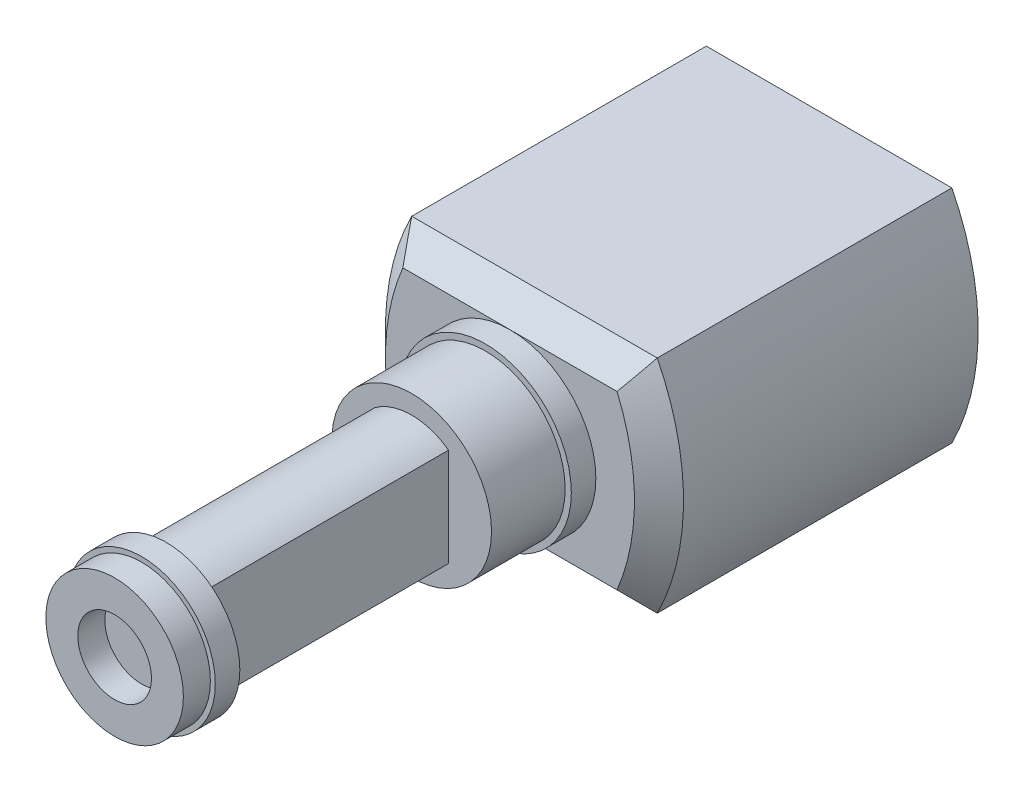
from build123d import *

# Parameters (mm, degrees)
BOSS_EXTRUDE1_DEPTH = 120
BOSS_EXTRUDE2_DEPTH = 10
BOSS_EXTRUDE2_TAPER = 45
SKETCH3_R           = 35
BOSS_EXTRUDE3_DEPTH = 10
SKETCH4_R           = 32.5
BOSS_EXTRUDE4_DEPTH = 30
BOSS_EXTRUDE5_DEPTH = 100
SKETCH6_R           = 30
BOSS_EXTRUDE6_DEPTH = 10
SKETCH7_R           = 28
BOSS_EXTRUDE7_DEPTH = 11
SKETCH8_R           = 40
BOSS_EXTRUDE8_DEPTH = 11
BOSS_EXTRUDE9_DEPTH = 55
SKETCH10_R          = 15
CUT_EXTRUDE1_DEPTH  = 11
SKETCH11_R          = 15
CUT_EXTRUDE2_DEPTH  = 20


with BuildPart() as part:
    # Sketch1 → Boss-Extrude1 (new body)
    with BuildSketch(Plane.XY):
        with BuildLine():
            Line((-50, 45), (50, 45))
            ThreePointArc((50, 45), (60.697144503, 0), (50, -45))
            Line((50, -45), (-50, -45))
            ThreePointArc((-50, -45), (-60.697144503, 0), (-50, 45))
        make_face()
    extrude(amount=BOSS_EXTRUDE1_DEPTH)

    # Sketch2 → Boss-Extrude2 (add)
    with BuildSketch(Plane.XY.offset(120)):
        with BuildLine():
            Line((-50, -45), (50, -45))
            ThreePointArc((50, -45), (60.697144503, 0), (50, 45))
            Line((50, 45), (-50, 45))
            ThreePointArc((-50, 45), (-60.697144503, 0), (-50, -45))
        make_face()
    extrude(amount=BOSS_EXTRUDE2_DEPTH, taper=BOSS_EXTRUDE2_TAPER)

    # Sketch3 → Boss-Extrude3 (add)
    with BuildSketch(Plane.XY.offset(130)):
        Circle(SKETCH3_R)
    extrude(amount=BOSS_EXTRUDE3_DEPTH)

    # Sketch4 → Boss-Extrude4 (add)
    with BuildSketch(Plane.XY.offset(140)):
        Circle(SKETCH4_R)
    extrude(amount=BOSS_EXTRUDE4_DEPTH)

    # Sketch5 → Boss-Extrude5 (add)
    with BuildSketch(Plane.XY.offset(170)):
        with BuildLine():
            Line((-15, 20), (-15, -20))
            ThreePointArc((-15, -20), (0, -24.86796738), (15, -20))
            Line((15, -20), (15, 20))
            ThreePointArc((15, 20), (0, 24.86796738), (-15, 20))
        make_face()
    extrude(amount=BOSS_EXTRUDE5_DEPTH)

    # Sketch6 → Boss-Extrude6 (add)
    with BuildSketch(Plane.XY.offset(270)):
        Circle(SKETCH6_R)
    extrude(amount=BOSS_EXTRUDE6_DEPTH)

    # Sketch7 → Boss-Extrude7 (add)
    with BuildSketch(Plane.XY.offset(280)):
        Circle(SKETCH7_R)
    extrude(amount=BOSS_EXTRUDE7_DEPTH)

    # Sketch8 → Boss-Extrude8 (add, symmetric)
    with BuildSketch(Plane.ZY.offset(50)):
        with Locations((60, -45)):
            Circle(SKETCH8_R)
    extrude(amount=BOSS_EXTRUDE8_DEPTH, both=True)

    # Sketch9 → Boss-Extrude9 (add)
    with BuildSketch(Plane(origin=(-39, 0, 0), x_dir=(0, 0, -1), z_dir=(1, 0, 0))):
        with BuildLine():
            Line((-85, -45), (-35, -45))
            Line((-35, -45), (-35, -72))
            ThreePointArc((-35, -72), (-60, -76.80636081), (-85, -72))
            Line((-85, -72), (-85, -45))
        make_face()
    extrude(amount=BOSS_EXTRUDE9_DEPTH)

    # Sketch10 → Cut-Extrude1 (cut)
    with BuildSketch(Plane.XY.offset(291)):
        Circle(SKETCH10_R)
    extrude(amount=-CUT_EXTRUDE1_DEPTH, mode=Mode.SUBTRACT)

    # Sketch11 → Cut-Extrude2 (cut)
    with BuildSketch(Plane.ZY.offset(61)):
        with Locations((60, -45)):
            Circle(SKETCH11_R)
    extrude(amount=-CUT_EXTRUDE2_DEPTH, mode=Mode.SUBTRACT)


solid = part.part
